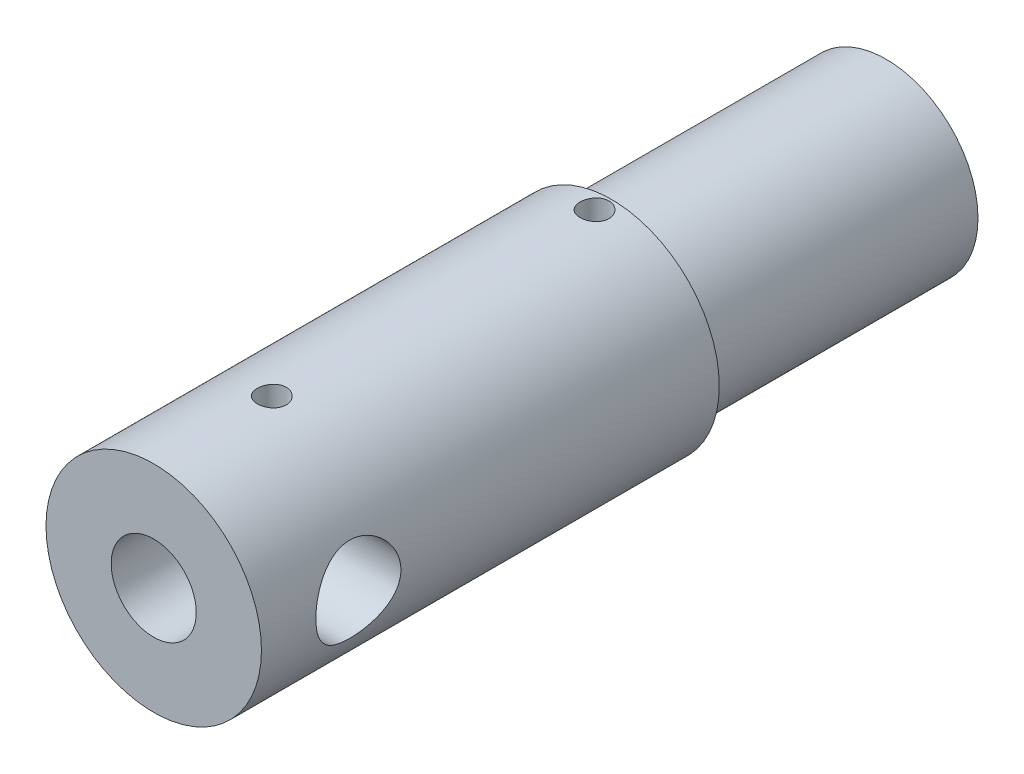
from build123d import *

# Parameters (mm, degrees)
SKETCH1_R          = 10.8204
SKETCH1_R_2        = 8.7122
EXTRUDE1_DEPTH     = 86.36
SKETCH2_R          = 12.7
SKETCH2_R_2        = 2.5908
EXTRUDE2_DEPTH     = 53.975
SKETCH3_R          = 8.7122
SKETCH3_R_2        = 6.5151
EXTRUDE3_DEPTH     = 35.3822
SKETCH4_R          = 8.7122
SKETCH4_R_2        = 6.5151
CUT_EXTRUDE1_DEPTH = 2.3876
SKETCH15_R         = 2.3622
CUT_EXTRUDE5_DEPTH = 7.2644
SKETCH17_R         = 1.7018
CUT_EXTRUDE6_DEPTH = 4.572
SKETCH18_R         = 5.0165
CUT_EXTRUDE7_DEPTH = 8.382
SKETCH19_R         = 5.0165
CUT_EXTRUDE8_DEPTH = 8.382


with BuildPart() as part:
    # Sketch1 → Extrude1 (new body)
    with BuildSketch(Plane.XY):
        Circle(SKETCH1_R)
        Circle(SKETCH1_R_2, mode=Mode.SUBTRACT)
    extrude(amount=EXTRUDE1_DEPTH)

    # Sketch2 → Extrude2 (add)
    with BuildSketch(Plane.XY.offset(86.36)):
        Circle(SKETCH2_R)
        Circle(SKETCH2_R_2, mode=Mode.SUBTRACT)
    extrude(amount=-EXTRUDE2_DEPTH)

    # Sketch3 → Extrude3 (add)
    with BuildSketch(Plane(origin=(0, 0, 0), x_dir=(-1, 0, 0), z_dir=(0, 0, -1))):
        Circle(SKETCH3_R)
        Circle(SKETCH3_R_2, mode=Mode.SUBTRACT)
    extrude(amount=-EXTRUDE3_DEPTH)

    # Sketch4 → Cut-Extrude1 (cut)
    with BuildSketch(Plane(origin=(0, 0, 0), x_dir=(-1, 0, 0), z_dir=(0, 0, -1))):
        Circle(SKETCH4_R)
        Circle(SKETCH4_R_2, mode=Mode.SUBTRACT)
    extrude(amount=-CUT_EXTRUDE1_DEPTH, mode=Mode.SUBTRACT)

    # Sketch15 → Cut-Extrude5 (cut)
    with BuildSketch(Plane(origin=(0, -12.7, 0), x_dir=(-1, 0, 0), z_dir=(0, 1, 0))):
        with Locations(Location((0, 38.8874, 0), (0, 0, 270))):  # turned: the seam where the file's is
            Circle(SKETCH15_R)
    extrude(amount=CUT_EXTRUDE5_DEPTH, mode=Mode.SUBTRACT)

    # Sketch17 → Cut-Extrude6 (cut)
    with BuildSketch(Plane(origin=(0, 12.7, 0), x_dir=(-1, 0, 0), z_dir=(0, 1, 0))):
        with Locations(Location((0, 34.3916, 0), (0, 0, 90))):  # turned: the seam where the file's is
            Circle(SKETCH17_R)
        with Locations(Location((0, 72.4408, 0), (0, 0, 90))):  # turned: the seam where the file's is
            Circle(SKETCH17_R)
    extrude(amount=-CUT_EXTRUDE6_DEPTH, mode=Mode.SUBTRACT)

    # Sketch18 → Cut-Extrude7 (cut)
    with BuildSketch(Plane.XY.offset(86.36)):
        Circle(SKETCH18_R)
    extrude(amount=-CUT_EXTRUDE7_DEPTH, mode=Mode.SUBTRACT)

    # Sketch19 → Cut-Extrude8 (cut)
    with BuildSketch(Plane(origin=(12.7, 0, 0), x_dir=(0, 0, -1), z_dir=(1, 0, 0))):
        with Locations(Location((-74.93, 0, 0), (0, 0, 180))):  # turned: the seam where the file's is
            Circle(SKETCH19_R)
    extrude(amount=-CUT_EXTRUDE8_DEPTH, mode=Mode.SUBTRACT)


solid = part.part
